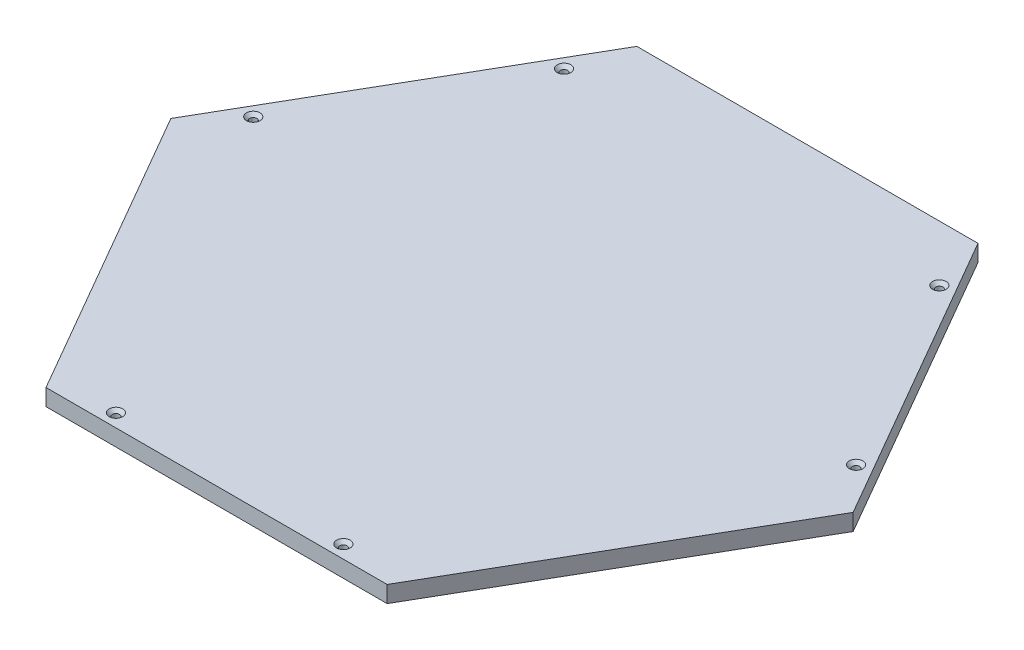
from build123d import *

# Parameters (mm, degrees)
BOSS_EXTRUDE1_DEPTH                             = 12.7
CSK_FOR_M5_FLAT_HEAD_MACHINE_SCREW1_D           = 5.5
CSK_FOR_M5_FLAT_HEAD_MACHINE_SCREW1_DEPTH       = 12.7
CSK_FOR_M5_FLAT_HEAD_MACHINE_SCREW1_CSINK_D     = 10.4
CSK_FOR_M5_FLAT_HEAD_MACHINE_SCREW1_CSINK_ANGLE = 90


with BuildPart() as part:
    # Sketch1 → Boss-Extrude1 (new body)
    with BuildSketch(Plane(origin=(0, 484.313360873, 0), x_dir=(1, 0, 0), z_dir=(0, 1, 0))):
        Polygon((1096.723413016, -1803.339072227), (966.247715506, -1577.348534986), (705.296320486, -1577.348534986), (574.820622976, -1803.339072227), (705.296320486, -2029.329609468), (966.247715506, -2029.329609468), align=None)
    extrude(amount=BOSS_EXTRUDE1_DEPTH)

    # CSK for M5 Flat Head Machine Screw1
    with Locations(Plane(origin=(0, 497.013360873, 0), x_dir=(1, 0, 0), z_dir=(0, 1, 0))):
        with Locations((605.218725769, -1770.688013736), (692.218725769, -1619.999593477), (979.325310224, -1619.999593477), (1066.325310224, -1770.688013736), (748.77757228, -2019.323746494), (922.777572027, -2019.31436283)):
            CounterSinkHole(CSK_FOR_M5_FLAT_HEAD_MACHINE_SCREW1_D / 2, CSK_FOR_M5_FLAT_HEAD_MACHINE_SCREW1_CSINK_D / 2, depth=CSK_FOR_M5_FLAT_HEAD_MACHINE_SCREW1_DEPTH, counter_sink_angle=CSK_FOR_M5_FLAT_HEAD_MACHINE_SCREW1_CSINK_ANGLE)


solid = part.part
